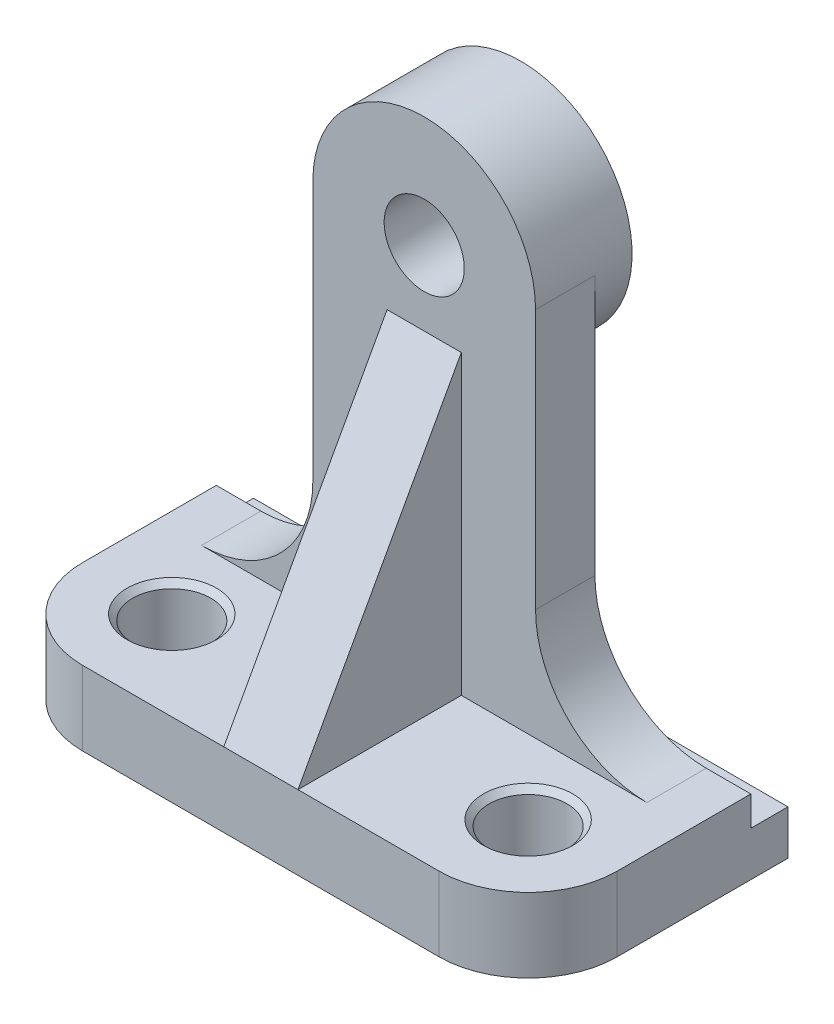
from build123d import *

# Parameters (mm, degrees)
SKETCH1_W                         = 72
SKETCH1_H                         = 35
BOSS_EXTRUDE1_DEPTH               = 10
SKETCH3_W                         = 72
SKETCH3_H                         = 5
CUT_EXTRUDE1_DEPTH                = 4
BOSS_EXTRUDE2_DEPTH               = 8
SKETCH5_R                         = 15
BOSS_EXTRUDE3_DEPTH               = 5
M12X1_25_TAPPED_HOLE1_D           = 10.8
M12X1_25_TAPPED_HOLE1_CSINK_D     = 12.05
M12X1_25_TAPPED_HOLE1_CSINK_ANGLE = 90
FILLET1_R                         = 15
SKETCH9_W                         = 10
SKETCH9_H                         = 22
BOSS_EXTRUDE4_DEPTH               = 40
CUT_EXTRUDE2_DEPTH                = 40
FILLET2_R                         = 12
M12X1_5_TAPPED_HOLE1_D            = 10.5
M12X1_5_TAPPED_HOLE1_CSINK_D      = 12.05
M12X1_5_TAPPED_HOLE1_CSINK_ANGLE  = 90


with BuildPart() as part:
    # Sketch1 → Boss-Extrude1 (new body)
    with BuildSketch(Plane(origin=(0, 0, 0), x_dir=(1, 0, 0), z_dir=(0, 1, 0))):
        with Locations((36, 17.5)):
            Rectangle(SKETCH1_W, SKETCH1_H)
    extrude(amount=BOSS_EXTRUDE1_DEPTH)

    # Sketch3 → Cut-Extrude1 (cut)
    with BuildSketch(Plane(origin=(0, 10, 0), x_dir=(1, 0, 0), z_dir=(0, 1, 0))):
        with Locations((36, 32.5)):
            Rectangle(SKETCH3_W, SKETCH3_H)
    extrude(amount=-CUT_EXTRUDE1_DEPTH, mode=Mode.SUBTRACT)

    # Sketch4 → Boss-Extrude2 (add)
    with BuildSketch(Plane(origin=(0, 0, -30), x_dir=(-1, 0, 0), z_dir=(0, 0, -1))):
        with BuildLine():
            Line((-51, 10), (-21, 10))
            Line((-21, 10), (-21, 60))
            ThreePointArc((-21, 60), (-36, 75), (-51, 60))
            Line((-51, 60), (-51, 10))
        make_face()
    extrude(amount=-BOSS_EXTRUDE2_DEPTH)

    # Sketch5 → Boss-Extrude3 (add)
    with BuildSketch(Plane(origin=(0, 0, -30), x_dir=(-1, 0, 0), z_dir=(0, 0, -1))):
        with Locations((-36, 60)):
            Circle(SKETCH5_R)
    extrude(amount=BOSS_EXTRUDE3_DEPTH)

    # M12x1.25 Tapped Hole1 (through all)
    with Locations(Plane(origin=(36, 60, -35), x_dir=(-1, 0, 0), z_dir=(0, 0, -1))):
        with Locations((0, 0)):
            CounterSinkHole(M12X1_25_TAPPED_HOLE1_D / 2, M12X1_25_TAPPED_HOLE1_CSINK_D / 2, counter_sink_angle=M12X1_25_TAPPED_HOLE1_CSINK_ANGLE)

    # Fillet1
    fillet1_edges = [part.edges().sort_by_distance(p)[0] for p in [
        (21, 10, -26),
        (51, 10, -26),
    ]]
    fillet(fillet1_edges, radius=FILLET1_R)

    # Sketch9 → Boss-Extrude4 (add)
    with BuildSketch(Plane(origin=(0, 10, 0), x_dir=(1, 0, 0), z_dir=(0, 1, 0))):
        with Locations((36, 11)):
            Rectangle(SKETCH9_W, SKETCH9_H)
    extrude(amount=BOSS_EXTRUDE4_DEPTH)

    # Sketch10 → Cut-Extrude2 (cut)
    with BuildSketch(Plane(origin=(41, 0, 0), x_dir=(0, 0, -1), z_dir=(1, 0, 0))):
        Polygon((22, 50), (0, 10), (0, 50), align=None)
    extrude(amount=-CUT_EXTRUDE2_DEPTH, mode=Mode.SUBTRACT)

    # Fillet2
    fillet2_edges = [part.edges().sort_by_distance(p)[0] for p in [
        (0, 5, 0),
        (72, 5, 0),
    ]]
    fillet(fillet2_edges, radius=FILLET2_R)

    # M12x1.5 Tapped Hole1 (through all)
    with Locations(Plane(origin=(12, 10, -12), x_dir=(0, 0, 1), z_dir=(0, 1, 0))):
        with Locations((0, 0), (0, 48)):
            CounterSinkHole(M12X1_5_TAPPED_HOLE1_D / 2, M12X1_5_TAPPED_HOLE1_CSINK_D / 2, counter_sink_angle=M12X1_5_TAPPED_HOLE1_CSINK_ANGLE)


solid = part.part
